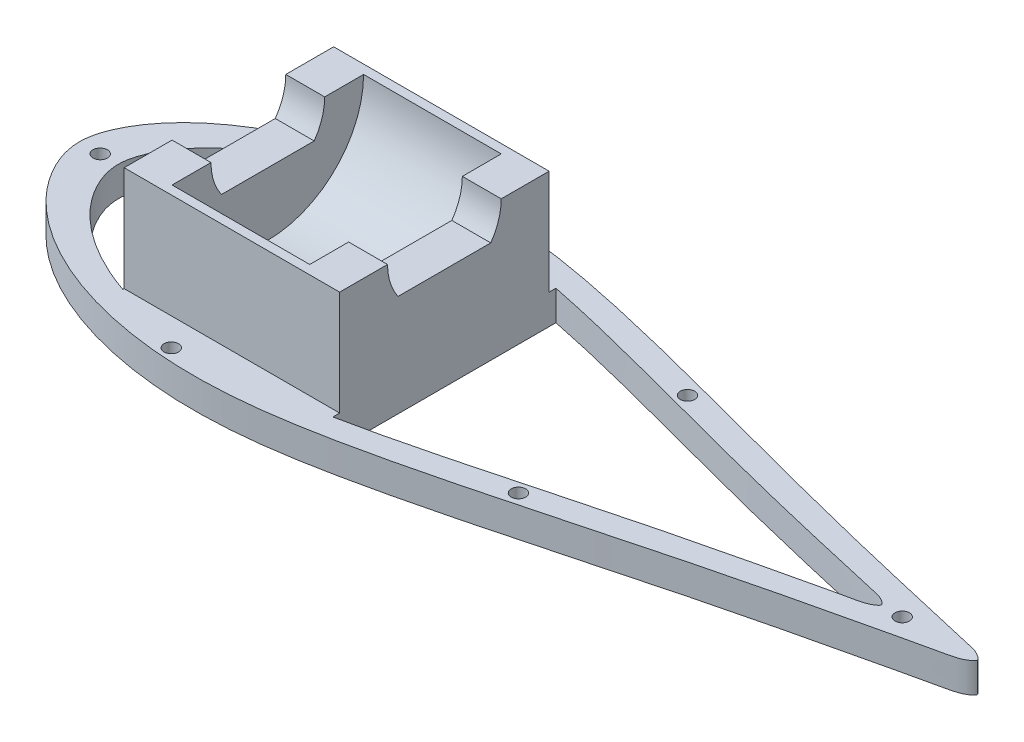
from build123d import *

# Parameters (mm, degrees)
BOSS_EXTRUDE1_DEPTH = 10
SKETCH5_W           = 72
SKETCH5_H           = 70
BOSS_EXTRUDE2_DEPTH = 70
SKETCH6_W           = 70
SKETCH6_H           = 35
CUT_EXTRUDE3_DEPTH  = 72
CUT_EXTRUDE4_DEPTH  = 13
SKETCH8_R           = 32
CUT_EXTRUDE5_DEPTH  = 46
CUT_EXTRUDE6_DEPTH  = 13
CUT_EXTRUDE7_DEPTH  = 10
SKETCH12_R          = 2.415
CUT_EXTRUDE8_DEPTH  = 10


with BuildPart() as part:
    # Sketch3 → Boss-Extrude1 (new body)
    with BuildSketch(Plane(origin=(0, 0, 0), x_dir=(1, 0, 0), z_dir=(0, 1, 0))):
        with BuildLine():
            add(Edge.make_bspline(
                [(0, 0), (0, -1.869412992), (0.64834316, -5.798703671), (3.031066686, -11.533576223), (6.653304031, -17.267010725), (11.471716912, -22.837096521), (17.430196145, -28.115434217), (24.465941762, -32.99859482), (32.527857891, -37.372315002), (41.538857724, -41.160691823), (51.431441971, -44.265106616), (62.11578082, -46.628168346), (73.525967425, -48.154878004), (85.611384032, -48.728354206), (98.342557923, -48.310477324), (111.725712529, -46.847858839), (125.760588908, -44.412209991), (140.434286751, -41.288720883), (155.634740935, -37.661490146), (171.176973505, -33.699494803), (186.853926113, -29.566356331), (202.431772576, -25.419418935), (217.9956614, -21.266300687), (233.208366579, -17.405000658), (247.68379827, -13.874815175), (260.725101784, -10.789740345), (272.105235179, -8.142980553), (281.711602995, -5.979406788), (289.207502575, -4.168959476), (295.036688315, -3.096938852), (298.170873437, -1.894998614), (300.577567682, 0), (298.170873437, 1.894998614), (295.036688315, 3.096938852), (289.207502575, 4.168959476), (281.711602995, 5.979406788), (272.105235179, 8.142980553), (260.725101784, 10.789740345), (247.68379827, 13.874815175), (233.208366579, 17.405000658), (217.9956614, 21.266300687), (202.431772576, 25.419418935), (186.853926113, 29.566356331), (171.176973505, 33.699494803), (155.634740935, 37.661490146), (140.434286751, 41.288720883), (125.760588908, 44.412209991), (111.725712529, 46.847858839), (98.342557923, 48.310477324), (85.611384032, 48.728354206), (73.525967425, 48.154878004), (62.11578082, 46.628168346), (51.431441971, 44.265106616), (41.538857724, 41.160691823), (32.527857891, 37.372315002), (24.465941762, 32.99859482), (17.430196145, 28.115434217), (11.471716912, 22.837096521), (6.653304031, 17.267010725), (3.031066686, 11.533576223), (0.64834316, 5.798703671), (0, 1.869412992), (0, 0)],
                knots=[0, 0, 0, 0, 0.008569339, 0.018011763, 0.028335072, 0.039554377, 0.051690855, 0.064762326, 0.078762966, 0.093695745, 0.109541044, 0.126268233, 0.143840833, 0.162293053, 0.181714548, 0.202223429, 0.224008172, 0.24704197, 0.271045998, 0.295701517, 0.320629039, 0.345429601, 0.369662175, 0.394534742, 0.417435645, 0.438026555, 0.456003621, 0.471089893, 0.483064812, 0.491749677, 0.497394866, 0.5, 0.502605134, 0.508250323, 0.516935188, 0.528910107, 0.543996379, 0.561973445, 0.582564355, 0.605465258, 0.630337825, 0.654570399, 0.679370961, 0.704298483, 0.728954002, 0.75295803, 0.775991828, 0.797776571, 0.818285452, 0.837706947, 0.856159167, 0.873731767, 0.890458956, 0.906304255, 0.921237034, 0.935237674, 0.948309145, 0.960445623, 0.971664928, 0.981988237, 0.991430661, 1, 1, 1, 1], degree=3))
        make_face()
    extrude(amount=BOSS_EXTRUDE1_DEPTH)

    # Sketch5 → Boss-Extrude2 (add)
    with BuildSketch(Plane(origin=(0, 10, 0), x_dir=(1, 0, 0), z_dir=(0, 1, 0))):
        with Locations((86, 0)):
            Rectangle(SKETCH5_W, SKETCH5_H)
    extrude(amount=BOSS_EXTRUDE2_DEPTH)

    # Sketch6 → Cut-Extrude3 (cut)
    with BuildSketch(Plane.ZY.offset(-50)):
        with Locations((0, 62.5)):
            Rectangle(SKETCH6_W, SKETCH6_H)
    extrude(amount=-CUT_EXTRUDE3_DEPTH, mode=Mode.SUBTRACT)

    # Sketch7 → Cut-Extrude4 (cut)
    with BuildSketch(Plane.ZY.offset(-50)):
        with BuildLine():
            Line((19, 45), (-19, 45))
            ThreePointArc((-19, 45), (-18.101750389, 39.227077617), (-15.491933385, 34))
            Line((-15.491933385, 34), (15.491933385, 34))
            ThreePointArc((15.491933385, 34), (18.101750389, 39.227077617), (19, 45))
        make_face()
    extrude(amount=-CUT_EXTRUDE4_DEPTH, mode=Mode.SUBTRACT)

    # Sketch8 → Cut-Extrude5 (cut)
    with BuildSketch(Plane.ZY.offset(-63)):
        with Locations((0, 45)):
            Circle(SKETCH8_R)
        with BuildLine():
            ThreePointArc((-19, 45), (-18.101750389, 50.772922383), (-15.491933385, 56))
            ThreePointArc((-15.491933385, 56), (0, 64), (15.491933385, 56))
            ThreePointArc((15.491933385, 56), (18.101750389, 50.772922383), (19, 45))
            ThreePointArc((19, 45), (18.101750389, 39.227077617), (15.491933385, 34))
            ThreePointArc((15.491933385, 34), (0, 26), (-15.491933385, 34))
            ThreePointArc((-15.491933385, 34), (-18.101750389, 39.227077617), (-19, 45))
        make_face(mode=Mode.SUBTRACT)
        with BuildLine():
            Line((15.491933385, 34), (-15.491933385, 34))
            ThreePointArc((-15.491933385, 34), (0, 26), (15.491933385, 34))
        make_face()
        with BuildLine():
            ThreePointArc((15.491933385, 34), (18.101750389, 39.227077617), (19, 45))
            Line((19, 45), (-19, 45))
            ThreePointArc((-19, 45), (-18.101750389, 39.227077617), (-15.491933385, 34))
            Line((-15.491933385, 34), (15.491933385, 34))
        make_face()
    extrude(amount=-CUT_EXTRUDE5_DEPTH, mode=Mode.SUBTRACT)

    # Sketch9 → Cut-Extrude6 (cut)
    with BuildSketch(Plane(origin=(122, 0, 0), x_dir=(0, 0, -1), z_dir=(1, 0, 0))):
        with BuildLine():
            Line((19, 45), (-19, 45))
            ThreePointArc((-19, 45), (-18.101750389, 39.227077617), (-15.491933385, 34))
            Line((-15.491933385, 34), (15.491933385, 34))
            ThreePointArc((15.491933385, 34), (18.101750389, 39.227077617), (19, 45))
        make_face()
    extrude(amount=-CUT_EXTRUDE6_DEPTH, mode=Mode.SUBTRACT)

    # Sketch10 → Cut-Extrude7 (cut)
    with BuildSketch(Plane(origin=(0, 10, 0), x_dir=(1, 0, 0), z_dir=(0, 1, 0))):
        with BuildLine():
            add(Edge.make_bspline(
                [(13.003087531, 0.00163068), (13.002933691, 0.47388298), (13.048257087, 1.427873487), (13.309111737, 3.33067748), (13.918224589, 5.67309173), (14.992172175, 8.369256975), (16.326326829, 10.943368887), (17.872563793, 13.393973735), (19.314193218, 15.332511218), (20.544318237, 16.820779182), (21.503126621, 17.905958878), (22.495464047, 18.960511652), (24.542350952, 21.009156574), (27.100246156, 23.225642621), (29.808332178, 25.246628335), (31.394451529, 26.347212068), (32.702865335, 27.212476373), (34.134334035, 28.109733404), (35.588715642, 28.969350744), (38.430491761, 30.563215926), (41.682353844, 32.163526711), (45.459360276, 33.767501218), (47.865790798, 34.697201438), (49.386513599, 35.238908761), (50, 35.450317413)],
                knots=[0.500052219, 0.500052219, 0.500052219, 0.500052219, 0.502604167, 0.505208333, 0.510416667, 0.515625, 0.520833333, 0.526041667, 0.53125, 0.533854167, 0.536458333, 0.5390625, 0.541666667, 0.552083333, 0.557291667, 0.559895833, 0.5625, 0.565755208, 0.569010417, 0.571614583, 0.583333333, 0.588541667, 0.59375, 0.597250755, 0.597250755, 0.597250755, 0.597250755], degree=3))
            Line((13.003087531, 0.00163068), (50, 0.006270358))
            Line((50, 0.006270358), (50, 35))
            Line((50, 35), (50, 35.450317413))
        make_face()
        with BuildLine():
            Line((50, 0.006270358), (13.003087531, 0.00163068))
            add(Edge.make_bspline(
                [(50, -35.438539687), (49.40705891, -35.234298657), (46.996940222, -34.377078037), (41.043632418, -31.973419887), (34.194980814, -28.351975623), (27.8811963, -23.889054172), (24.224808239, -20.726507209), (21.529273815, -17.958631384), (19.641981845, -15.760246719), (17.910042926, -13.436933958), (16.360641575, -10.9894108), (15.01745604, -8.41827748), (13.939375502, -5.725306126), (13.198214011, -2.919310352), (13.004360505, -0.98153134), (13.003090679, -0.008032749), (13.003087531, 0.00163068)],
                knots=[0.4028669, 0.4028669, 0.4028669, 0.4028669, 0.40625, 0.416666667, 0.4375, 0.447916667, 0.458333333, 0.463541667, 0.46875, 0.473958333, 0.479166667, 0.484375, 0.489583333, 0.494791667, 0.5, 0.500052219, 0.500052219, 0.500052219, 0.500052219], degree=3))
            Line((50, -35.438539687), (50, -35))
            Line((50, -35), (50, 0.006270358))
        make_face()
        with BuildLine():
            Line((122, 0.015299673), (267.994071473, 0.033608374))
            add(Edge.make_bspline(
                [(267.993833139, 0.037621373), (267.993918034, 0.036283971), (267.993997476, 0.034946294), (267.994071473, 0.033608374)],
                knots=[0, 0, 0, 0, 7.445e-06, 7.445e-06, 7.445e-06, 7.445e-06], degree=3))
            add(Edge.make_bspline(
                [(122, 37.262963938), (122.142126515, 37.234578919), (123.230824923, 37.016443861), (125.264168319, 36.599126479), (128.096856433, 35.996065376), (130.925522422, 35.374395038), (134.69214394, 34.523259728), (139.392006006, 33.422613932), (145.020684108, 32.055817947), (150.640028107, 30.650967772), (156.251915239, 29.216366196), (163.726954902, 27.274663119), (171.193702741, 25.301487395), (178.656857036, 23.314707609), (184.253578098, 21.822183729), (189.851033352, 20.332466039), (195.451402138, 18.853992765), (202.925237399, 16.908463564), (212.284839749, 14.543698901), (221.663759249, 12.256238488), (229.175755944, 10.462988451), (234.813425651, 9.133642994), (239.514645654, 8.039466576), (242.807685477, 7.283025162), (244.689770792, 6.852281263), (246.101371173, 6.529376455), (247.27764471, 6.260022363), (248.453794529, 5.990125018), (249.394570134, 5.773574431), (250.570263659, 5.501676646), (251.745592557, 5.228182496), (253.155448859, 4.897627385), (255.035425982, 4.457652319), (256.916508065, 4.022396946), (258.802362573, 3.608884851), (260.220747919, 3.31731839), (261.63978248, 3.027368212), (262.818915453, 2.766822198), (263.754998196, 2.52732477), (264.450323904, 2.324150898), (265.134709774, 2.088529125), (265.690088473, 1.854173073), (266.122670871, 1.640967584), (266.440807248, 1.468623963), (266.752184556, 1.283987144), (267.005595707, 1.11998632), (267.204544503, 0.98290554), (267.351136846, 0.876246792), (267.493641346, 0.763912187), (267.630615986, 0.644176027), (267.738094756, 0.536231383), (267.816944045, 0.443217292), (267.870839255, 0.369673202), (267.91790645, 0.291969637), (267.956056183, 0.210223025), (267.978531458, 0.139261053), (267.989745862, 0.0814145), (267.992905119, 0.052241032), (267.993833139, 0.037621373)],
                knots=[0.728384756, 0.728384756, 0.728384756, 0.728384756, 0.729166667, 0.734375, 0.739583333, 0.744791667, 0.75, 0.760416667, 0.770833333, 0.78125, 0.791666667, 0.802083333, 0.822916667, 0.833333333, 0.84375, 0.854166667, 0.864583333, 0.875, 0.895833333, 0.916666667, 0.927083333, 0.9375, 0.947916667, 0.953125, 0.955729167, 0.958333333, 0.9609375, 0.962239583, 0.96484375, 0.966145833, 0.96875, 0.971354167, 0.973958333, 0.979166667, 0.981770833, 0.984375, 0.986979167, 0.989583333, 0.990885417, 0.9921875, 0.993489583, 0.994791667, 0.995442708, 0.99609375, 0.996744792, 0.997395833, 0.997721354, 0.998046875, 0.998372396, 0.998697917, 0.999023438, 0.999186198, 0.999348958, 0.999511719, 0.999674479, 0.99983724, 0.99991862, 1, 1, 1, 1], degree=3))
            Line((122, 37.262963938), (122, 35))
            Line((122, 35), (122, 0.015299673))
        make_face()
        with BuildLine():
            add(Edge.make_bspline(
                [(267.994071473, 0.033608374), (267.995615261, 0.005695637), (267.993923562, -0.051684397), (267.979713902, -0.122748012), (267.957078698, -0.193497655), (267.933048449, -0.248539132), (267.897095853, -0.314953343), (267.855927684, -0.37888929), (267.781879387, -0.475690427), (267.699151251, -0.564939071), (267.611371274, -0.648673548), (267.543528936, -0.70909602), (267.473988334, -0.767436788), (267.332060375, -0.880510846), (267.111129501, -1.039345791), (266.858976714, -1.205285519), (266.653456424, -1.33183303), (266.445533284, -1.454255566), (266.181276983, -1.599537598), (265.857754303, -1.761472436), (265.528353324, -1.910970071), (265.193634718, -2.048080378), (264.854322018, -2.173438895), (264.396841465, -2.326992231), (263.817639672, -2.497593186), (263.116745368, -2.680117783), (262.412055865, -2.84665763), (261.468800091, -3.05318611), (259.811880305, -3.386905797), (257.450333413, -3.885416334), (254.629797965, -4.542536412), (251.809749811, -5.20194666), (248.988228949, -5.855079535), (246.16527231, -6.501971114), (243.342382791, -7.149165703), (240.9903698, -7.690210325), (239.109244389, -8.125152053), (236.288046629, -8.779688294), (232.998070199, -9.549451745), (228.300524368, -10.659444435), (223.605448465, -11.779904243), (217.975879503, -13.143191021), (210.476672328, -14.98884442), (201.117030713, -17.35343775), (189.913564789, -20.300023218), (180.586615551, -22.79100541), (173.123346339, -24.777309168), (167.524232992, -26.260787258), (161.922226004, -27.733354096), (156.316051071, -29.190006841), (150.704170792, -30.624518154), (143.21163935, -32.497143299), (135.700808797, -34.296282397), (128.163235773, -35.980017798), (124.220409535, -36.806571369), (122.163597597, -37.219290587), (122, -37.251998228)],
                knots=[7.445e-06, 7.445e-06, 7.445e-06, 7.445e-06, 0.00016276, 0.000325521, 0.000406901, 0.000569661, 0.000651042, 0.000813802, 0.000976562, 0.001302083, 0.001464844, 0.001627604, 0.001790365, 0.001953125, 0.002604167, 0.003255208, 0.003580729, 0.00390625, 0.004557292, 0.005208333, 0.005859375, 0.006510417, 0.007161458, 0.0078125, 0.009114583, 0.010416667, 0.01171875, 0.013020833, 0.015625, 0.020833333, 0.026041667, 0.03125, 0.036458333, 0.041666667, 0.046875, 0.052083333, 0.0546875, 0.057291667, 0.067708333, 0.072916667, 0.083333333, 0.09375, 0.104166667, 0.125, 0.145833333, 0.166666667, 0.177083333, 0.1875, 0.197916667, 0.208333333, 0.21875, 0.229166667, 0.25, 0.260416667, 0.270833333, 0.271733321, 0.271733321, 0.271733321, 0.271733321], degree=3))
            Line((267.994071473, 0.033608374), (122, 0.015299673))
            Line((122, 0.015299673), (122, -35))
            Line((122, -35), (122, -37.251998228))
        make_face()
    extrude(amount=-CUT_EXTRUDE7_DEPTH, mode=Mode.SUBTRACT)

    # Sketch12 → Cut-Extrude8 (cut)
    with BuildSketch(Plane(origin=(0, 10, 0), x_dir=(1, 0, 0), z_dir=(0, 1, 0))):
        with BuildLine():
            ThreePointArc((272.585, 0), (275, -2.415), (277.415, 0))
            Line((277.415, 0), (272.585, 0))
        make_face()
        with BuildLine():
            Line((272.585, 0), (277.415, 0))
            ThreePointArc((277.415, 0), (275, 2.415), (272.585, 0))
        make_face()
        with Locations(Location((75, 44.25, 0), (0, 0, 270))):
            Circle(SKETCH12_R)
        with BuildLine():
            ThreePointArc((4.585, 0), (7, -2.415), (9.415, 0))
            Line((9.415, 0), (4.585, 0))
        make_face()
        with BuildLine():
            Line((4.585, 0), (9.415, 0))
            ThreePointArc((9.415, 0), (7, 2.415), (4.585, 0))
        make_face()
        with Locations(Location((75, -44.25, 0), (0, 0, 270))):
            Circle(SKETCH12_R)
        with Locations(Location((175, -28.25, 0), (0, 0, 270))):
            Circle(SKETCH12_R)
        with Locations(Location((175, 28.25, 0), (0, 0, 90))):
            Circle(SKETCH12_R)
    extrude(amount=-CUT_EXTRUDE8_DEPTH, mode=Mode.SUBTRACT)


solid = part.part
